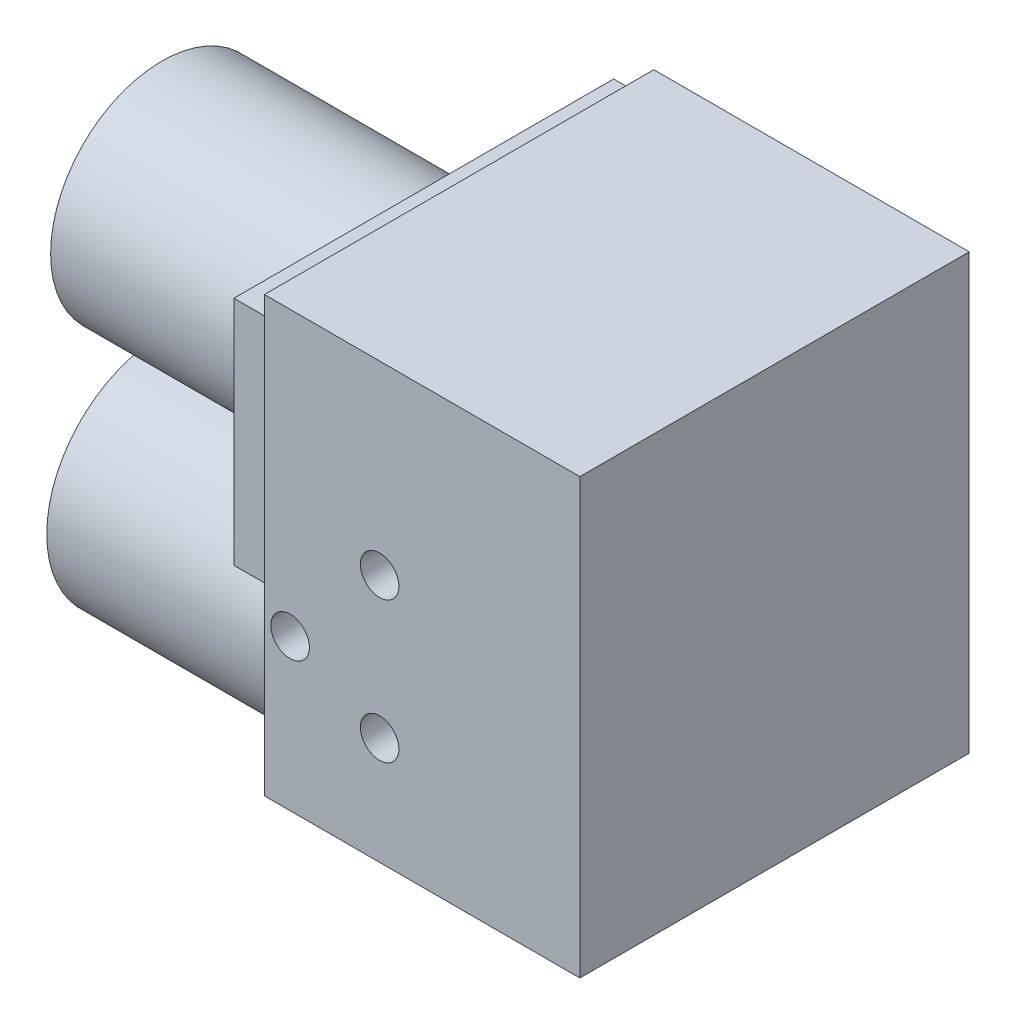
from build123d import *

# Parameters (mm, degrees)
SKETCH2_W                        = 98.18
SKETCH2_H                        = 135.15
BOSS_EXTRUDE1_DEPTH              = 55.6
BOSS_EXTRUDE1_DEPTH_BACK         = 65.6
SKETCH3_R                        = 34.65
SKETCH3_R_2                      = 35.85
BOSS_EXTRUDE2_DEPTH              = 87.5
TAP_DRILL_FOR_M14X2_0_TAP1_D     = 12
TAP_DRILL_FOR_M14X2_0_TAP1_DEPTH = 19.56
TAP_DRILL_FOR_M14X2_0_TAP1_TIP   = 3.605163714
TAP_DRILL_FOR_M12X1_5_TAP2_D     = 10.5
TAP_DRILL_FOR_M12X1_5_TAP2_DEPTH = 19.56
TAP_DRILL_FOR_M12X1_5_TAP2_TIP   = 3.15451825
SKETCH8_W                        = 118.2
SKETCH8_H                        = 72
BOSS_EXTRUDE3_DEPTH              = 11
TAP_DRILL_FOR_M12X1_5_TAP3_D     = 10.5
TAP_DRILL_FOR_M12X1_5_TAP3_DEPTH = 19.56
TAP_DRILL_FOR_M12X1_5_TAP3_TIP   = 3.15451825


with BuildPart() as part:
    # Sketch2 → Boss-Extrude1 (new body, two sides)
    with BuildSketch(Plane.XY) as boss_extrude1_sk:
        Rectangle(SKETCH2_W, SKETCH2_H)
    extrude(amount=BOSS_EXTRUDE1_DEPTH)
    extrude(boss_extrude1_sk.sketch, amount=-BOSS_EXTRUDE1_DEPTH_BACK)

    # Sketch3 → Boss-Extrude2 (add)
    with BuildSketch(Plane.ZY.offset(49.09)):
        with Locations((0, 24.325)):
            Circle(SKETCH3_R)
        with Locations((0, -50.675)):
            Circle(SKETCH3_R_2)
    extrude(amount=BOSS_EXTRUDE2_DEPTH)

    # Tap Drill for M14x2.0 Tap1
    with Locations(Plane.XY.offset(55.6)):
        with Locations((-13.23, 9.825), (-13.23, -34.075), (-41.09, -20.575)):
            Hole(TAP_DRILL_FOR_M14X2_0_TAP1_D / 2, depth=TAP_DRILL_FOR_M14X2_0_TAP1_DEPTH)
            with Locations((0, 0, -(TAP_DRILL_FOR_M14X2_0_TAP1_DEPTH + TAP_DRILL_FOR_M14X2_0_TAP1_TIP / 2))):  # 118° drill point
                Cone(0, TAP_DRILL_FOR_M14X2_0_TAP1_D / 2, TAP_DRILL_FOR_M14X2_0_TAP1_TIP, mode=Mode.SUBTRACT)

    # Tap Drill for M12x1.5 Tap2
    with Locations(Plane(origin=(0, -67.575, 0), x_dir=(-1, 0, 0), z_dir=(0, -1, 0))):
        with Locations((32.79, -35.1), (36.39, 57.2)):
            Hole(TAP_DRILL_FOR_M12X1_5_TAP2_D / 2, depth=TAP_DRILL_FOR_M12X1_5_TAP2_DEPTH)
            with Locations((0, 0, -(TAP_DRILL_FOR_M12X1_5_TAP2_DEPTH + TAP_DRILL_FOR_M12X1_5_TAP2_TIP / 2))):  # 118° drill point
                Cone(0, TAP_DRILL_FOR_M12X1_5_TAP2_D / 2, TAP_DRILL_FOR_M12X1_5_TAP2_TIP, mode=Mode.SUBTRACT)

    # Sketch8 → Boss-Extrude3 (add)
    with BuildSketch(Plane.ZY.offset(49.09)):
        with Locations((-5, 24.325)):
            Rectangle(SKETCH8_W, SKETCH8_H)
    extrude(amount=BOSS_EXTRUDE3_DEPTH)

    # Tap Drill for M12x1.5 Tap3
    with Locations(Plane.ZY.offset(60.09)):
        with Locations((-49.6, 52.175), (-55.1, 6.075), (45.1, 6.075), (39.6, 52.175)):
            Hole(TAP_DRILL_FOR_M12X1_5_TAP3_D / 2, depth=TAP_DRILL_FOR_M12X1_5_TAP3_DEPTH)
            with Locations((0, 0, -(TAP_DRILL_FOR_M12X1_5_TAP3_DEPTH + TAP_DRILL_FOR_M12X1_5_TAP3_TIP / 2))):  # 118° drill point
                Cone(0, TAP_DRILL_FOR_M12X1_5_TAP3_D / 2, TAP_DRILL_FOR_M12X1_5_TAP3_TIP, mode=Mode.SUBTRACT)


solid = part.part
